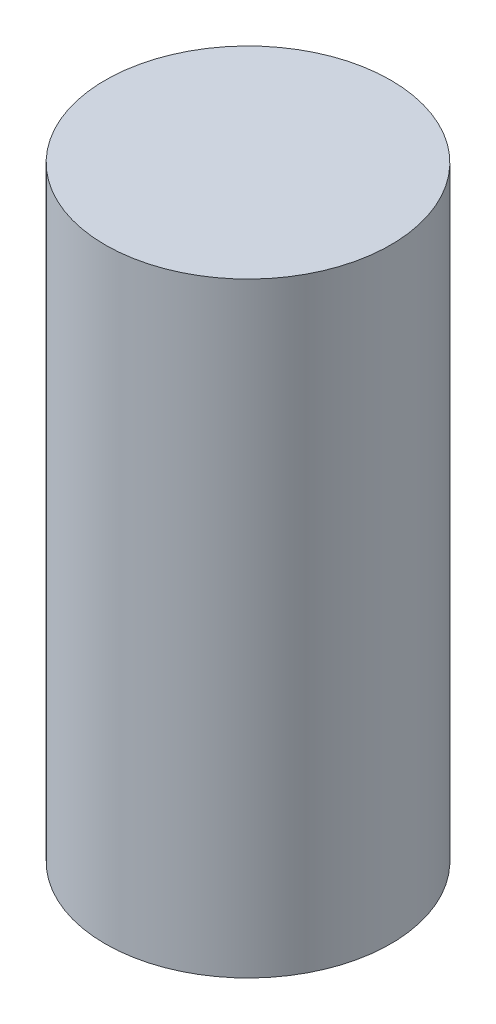
from build123d import *

# Parameters (mm, degrees)
SKETCH2_R           = 31.75
BOSS_EXTRUDE1_DEPTH = 134.62


with BuildPart() as part:
    # Sketch2 → Boss-Extrude1 (new body)
    with BuildSketch(Plane(origin=(0, 0, 0), x_dir=(1, 0, 0), z_dir=(0, 1, 0))):
        Circle(SKETCH2_R)
    extrude(amount=BOSS_EXTRUDE1_DEPTH)


solid = part.part
